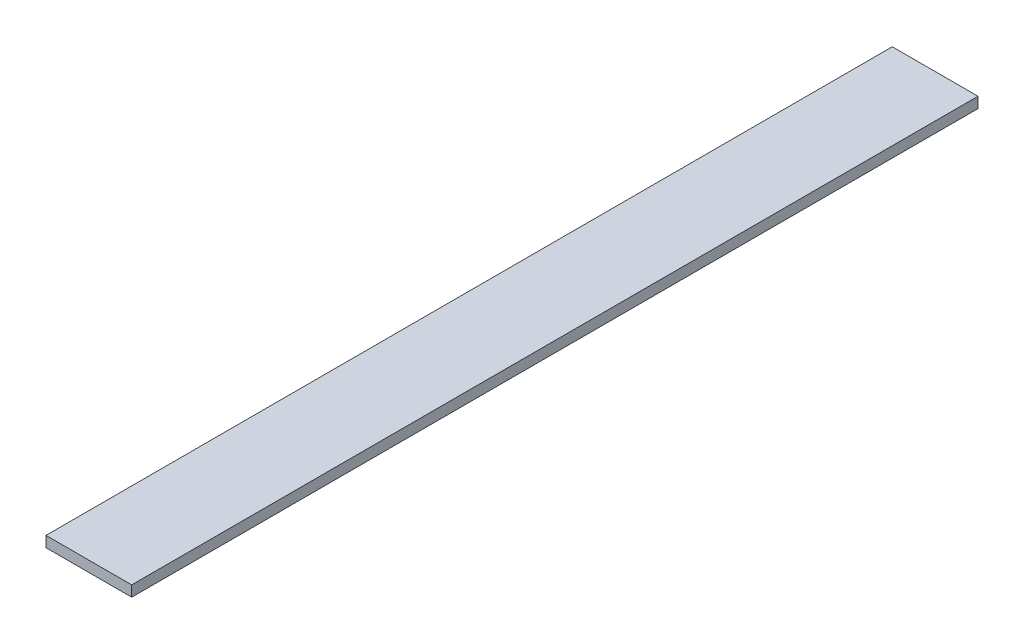
from build123d import *

# Parameters (mm, degrees)
SKETCH1_W           = 50.8
SKETCH1_H           = 501.65
BOSS_EXTRUDE1_DEPTH = 6.35


with BuildPart() as part:
    # Sketch1 → Boss-Extrude1 (new body)
    with BuildSketch(Plane(origin=(0, 0, 0), x_dir=(1, 0, 0), z_dir=(0, 1, 0))):
        Rectangle(SKETCH1_W, SKETCH1_H)
    extrude(amount=BOSS_EXTRUDE1_DEPTH)


solid = part.part
